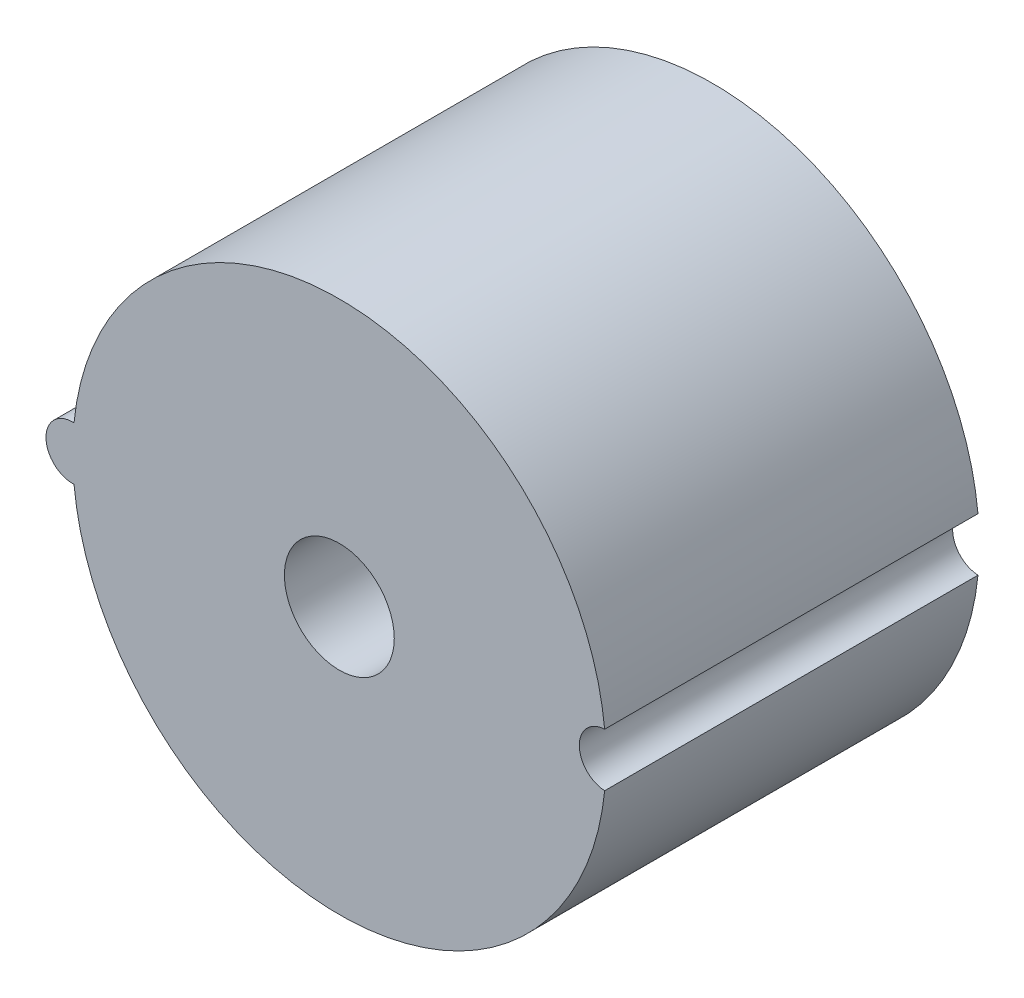
from build123d import *

# Parameters (mm, degrees)
SKETCH1_R           = 15.875
BOSS_EXTRUDE1_DEPTH = 22.225
SKETCH1_3_R         = 10.795
CUT_EXTRUDE1_DEPTH  = 5.08
BOSS_EXTRUDE2_START = 5.08
SKETCH1_4_R         = 5.08
BOSS_EXTRUDE2_DEPTH = 0.889
BOSS_EXTRUDE3_START = 5.08
SKETCH1_5_R         = 3.175
BOSS_EXTRUDE3_DEPTH = 6.35
SKETCH2_R           = 3.27025
CUT_EXTRUDE2_DEPTH  = 12.7
SKETCH3_R           = 1.5875
CUT_EXTRUDE4_DEPTH  = 24.495
SKETCH3_3_R         = 1.5875
BOSS_EXTRUDE4_DEPTH = 22.225


with BuildPart() as part:
    # Sketch1 → Boss-Extrude1 (new body)
    with BuildSketch(Plane.XY):
        Circle(SKETCH1_R)
    extrude(amount=BOSS_EXTRUDE1_DEPTH)

    # Sketch1_3 → Cut-Extrude1 (cut)
    with BuildSketch(Plane.XY):
        Circle(SKETCH1_3_R)
    extrude(amount=CUT_EXTRUDE1_DEPTH, mode=Mode.SUBTRACT)

    # Sketch1_4 → Boss-Extrude2 (add)
    with BuildSketch(Plane.XY.offset(BOSS_EXTRUDE2_START)):
        Circle(SKETCH1_4_R)
    extrude(amount=-BOSS_EXTRUDE2_DEPTH)

    # Sketch1_5 → Boss-Extrude3 (add)
    with BuildSketch(Plane.XY.offset(BOSS_EXTRUDE3_START)):
        Circle(SKETCH1_5_R)
    extrude(amount=-BOSS_EXTRUDE3_DEPTH)

    # Sketch2 → Cut-Extrude2 (cut)
    with BuildSketch(Plane.XY.offset(22.225)):
        Circle(SKETCH2_R)
    extrude(amount=-CUT_EXTRUDE2_DEPTH, mode=Mode.SUBTRACT)

    # Sketch3 → Cut-Extrude4 (cut, through all)
    with BuildSketch(Plane.XY.offset(22.225)):
        with Locations((15.875, 0)):
            Circle(SKETCH3_R)
    extrude(amount=-CUT_EXTRUDE4_DEPTH, mode=Mode.SUBTRACT)

    # Sketch3_3 → Boss-Extrude4 (add)
    with BuildSketch(Plane.XY.offset(22.225)):
        with Locations((-15.875, 0)):
            Circle(SKETCH3_3_R)
    extrude(amount=-BOSS_EXTRUDE4_DEPTH)


solid = part.part
